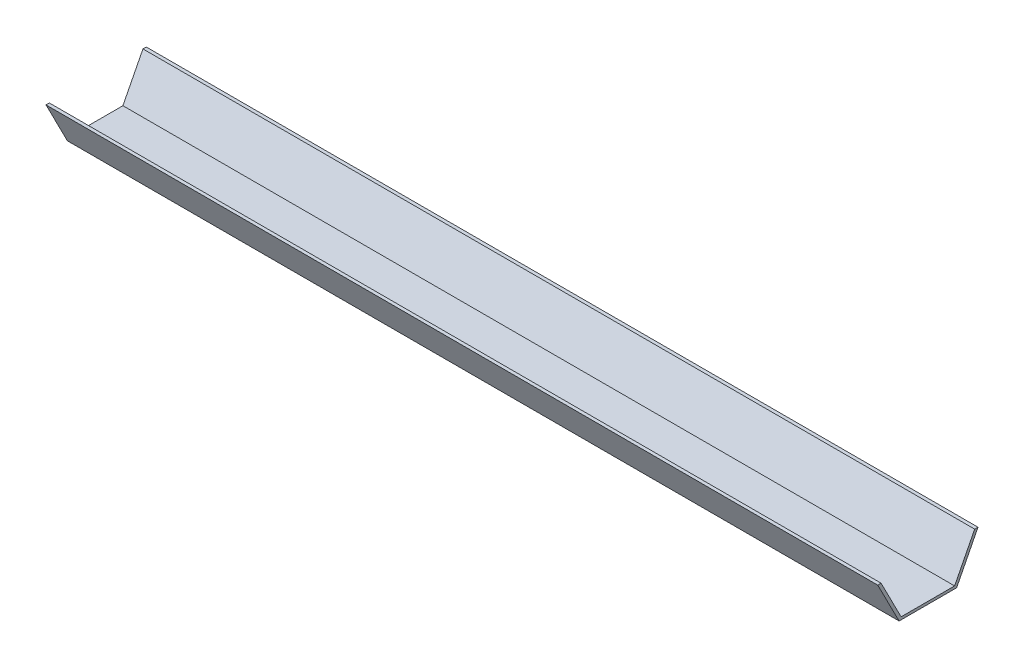
from build123d import *

# Parameters (mm, degrees)
BOSS_EXTRUDE1_DEPTH = 375


with BuildPart() as part:
    # Sketch1 → Boss-Extrude1 (new body)
    with BuildSketch(Plane(origin=(0, 0, 0), x_dir=(0, 0, -1), z_dir=(1, 0, 0))):
        Polygon((1.507263275, 0), (11.144498003, 18.846147913), (9.637234728, 18.846147913), (0.607157722, 1.187330657), (-23.522360298, 1.187330657), (-32.552437304, 18.846147913), (-34.062437304, 18.846147913), (-24.425202576, 0), align=None)
    extrude(amount=BOSS_EXTRUDE1_DEPTH)


solid = part.part
